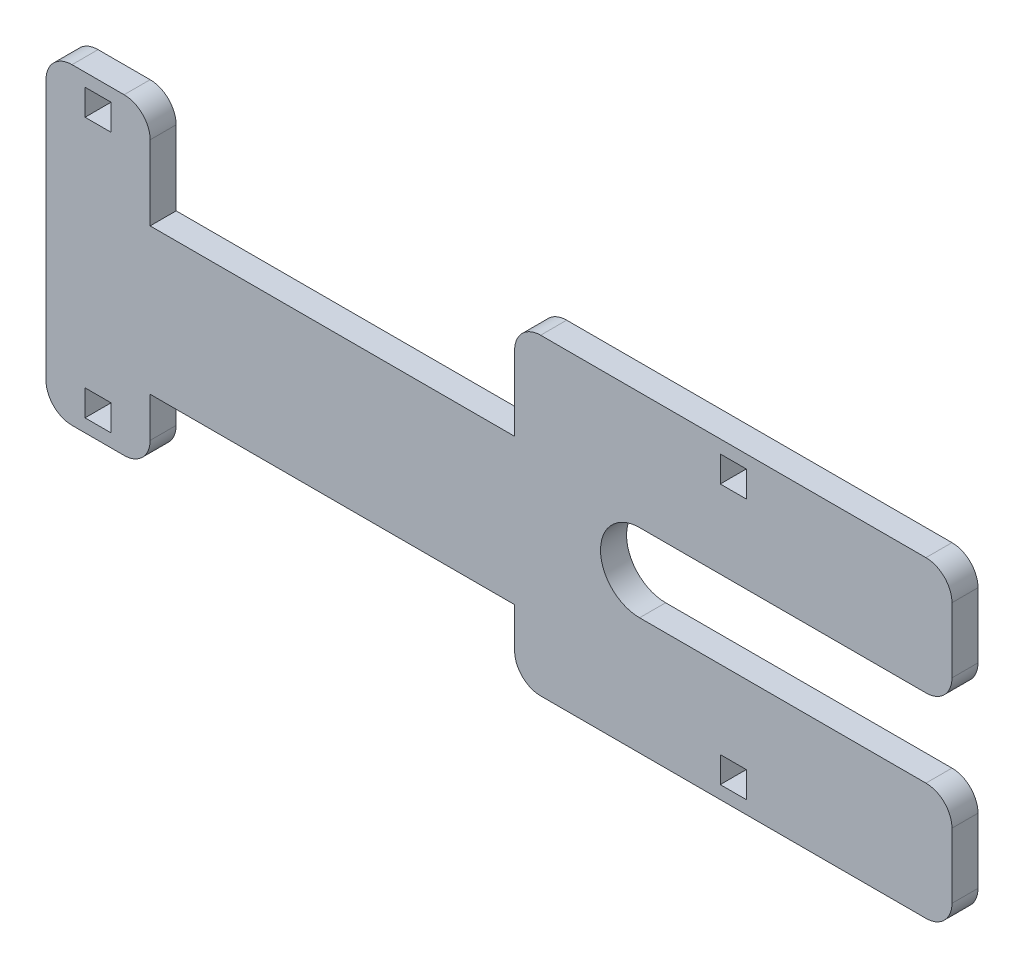
from build123d import *

# Parameters (mm, degrees)
BOSS_EXTRUDE1_DEPTH     = 3.175
SKETCH2_W               = 3.175
SKETCH2_H               = 3.175
CUT_EXTRUDE1_DEPTH      = 1
CUT_EXTRUDE1_DEPTH_BACK = 4.175


with BuildPart() as part:
    # Sketch1 → Boss-Extrude1 (new body)
    with BuildSketch(Plane.XY):
        with BuildLine():
            Line((15.24, 15.7607), (50.165, 15.7607))
            ThreePointArc((50.165, 15.7607), (52.41006403, 16.69063597), (53.34, 18.9357))
            Line((53.34, 18.9357), (53.34, 26.8732))
            ThreePointArc((53.34, 26.8732), (52.41006403, 29.11826403), (50.165, 30.0482))
            Line((50.165, 30.0482), (3.175, 30.0482))
            ThreePointArc((3.175, 30.0482), (0.92993597, 29.11826403), (0, 26.8732))
            Line((0, 26.8732), (0, 17.78))
            Line((0, 17.78), (-44.45, 17.78))
            Line((-44.45, 17.78), (-44.45, 26.8732))
            ThreePointArc((-44.45, 26.8732), (-45.37993597, 29.11826403), (-47.625, 30.0482))
            Line((-47.625, 30.0482), (-53.975, 30.0482))
            ThreePointArc((-53.975, 30.0482), (-56.22006403, 29.11826403), (-57.15, 26.8732))
            Line((-57.15, 26.8732), (-57.15, -4.8768))
            ThreePointArc((-57.15, -4.8768), (-56.22006403, -7.12186403), (-53.975, -8.0518))
            Line((-53.975, -8.0518), (-47.625, -8.0518))
            ThreePointArc((-47.625, -8.0518), (-45.37993597, -7.12186403), (-44.45, -4.8768))
            Line((-44.45, -4.8768), (-44.45, 0))
            Line((-44.45, 0), (0, 0))
            Line((0, 0), (0, -4.8768))
            ThreePointArc((0, -4.8768), (0.92993597, -7.12186403), (3.175, -8.0518))
            Line((3.175, -8.0518), (50.165, -8.0518))
            ThreePointArc((50.165, -8.0518), (52.41006403, -7.12186403), (53.34, -4.8768))
            Line((53.34, -4.8768), (53.34, 3.0607))
            ThreePointArc((53.34, 3.0607), (52.41006403, 5.30576403), (50.165, 6.2357))
            Line((50.165, 6.2357), (15.24, 6.2357))
            ThreePointArc((15.24, 6.2357), (10.4775, 10.9982), (15.24, 15.7607))
        make_face()
    extrude(amount=BOSS_EXTRUDE1_DEPTH)

    # Sketch2 → Cut-Extrude1 (cut, two sides)
    with BuildSketch(Plane.XY.offset(3.175)) as cut_extrude1_sk:
        with Locations((26.67, -4.8768)):
            Rectangle(SKETCH2_W, SKETCH2_H)
        with Locations((-50.8, 26.8732)):
            Rectangle(SKETCH2_W, SKETCH2_H)
        with Locations((26.67, 26.8732)):
            Rectangle(SKETCH2_W, SKETCH2_H)
        with Locations((-50.8, -4.8768)):
            Rectangle(SKETCH2_W, SKETCH2_H)
    extrude(amount=CUT_EXTRUDE1_DEPTH, mode=Mode.SUBTRACT)
    extrude(cut_extrude1_sk.sketch, amount=-CUT_EXTRUDE1_DEPTH_BACK, mode=Mode.SUBTRACT)


solid = part.part
